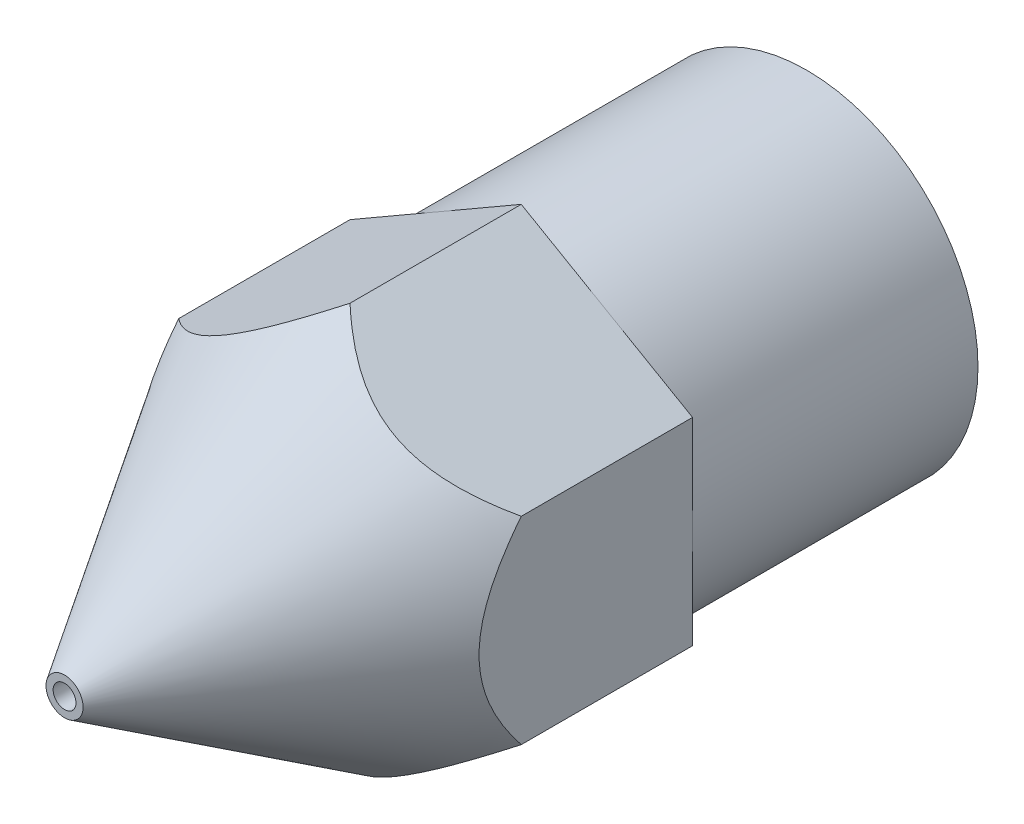
from build123d import *

# Parameters (mm, degrees)
SKETCH4_OUTSIDE_W  = 12.184
SKETCH4_OUTSIDE_H  = 12.184
CUT_EXTRUDE5_DEPTH = 14


with BuildPart() as part:
    # Sketch1 → Revolve2 (revolve)
    with BuildSketch(Plane(origin=(0, 0, 0), x_dir=(0, 0, -1), z_dir=(1, 0, 0))):
        Polygon((0, 0.2), (0, 0.325), (5, 3.464101615), (8, 3.464101615), (8, 3), (13, 3), (13, 1), (3, 1), (0.5, 0.2), align=None)
    revolve(axis=Axis((0, 0, 0), (0, 0, -1)))

    # Sketch4 outside → Cut-Extrude5 (cut, through all)
    with BuildSketch(Plane.XY):
        Rectangle(SKETCH4_OUTSIDE_W, SKETCH4_OUTSIDE_H)
        Polygon((0, 3.464101615), (-3, 1.732050808), (-3, -1.732050808), (0, -3.464101615), (3, -1.732050808), (3, 1.732050808), align=None, mode=Mode.SUBTRACT)
    extrude(amount=-CUT_EXTRUDE5_DEPTH, mode=Mode.SUBTRACT)


solid = part.part
